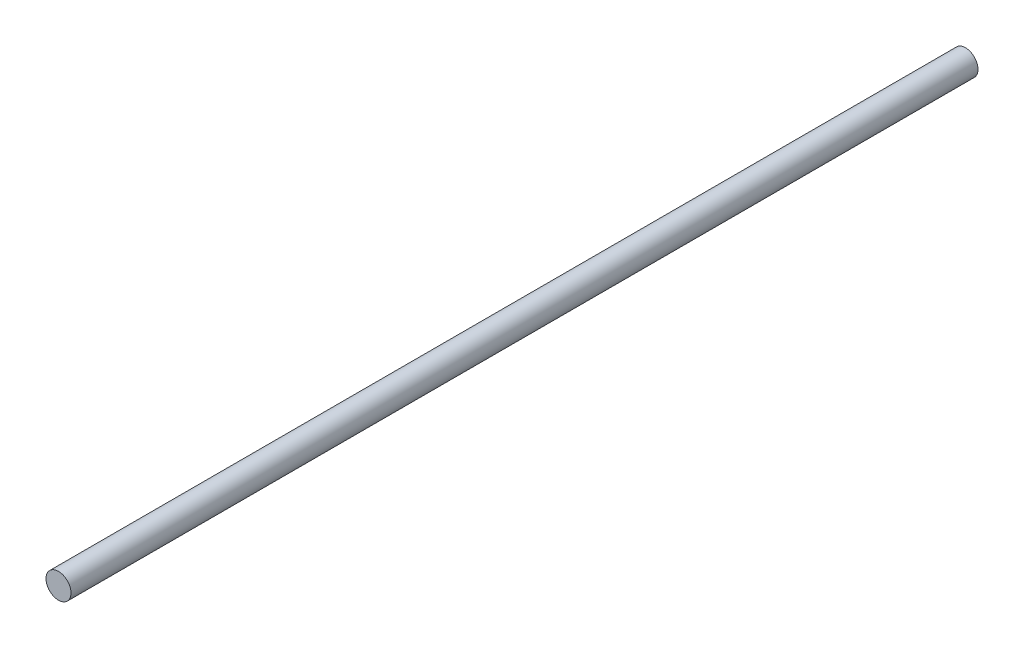
from build123d import *

# Parameters (mm, degrees)
SKETCH1_R           = 4
BOSS_EXTRUDE1_DEPTH = 290


with BuildPart() as part:
    # Sketch1 → Boss-Extrude1 (new body)
    with BuildSketch(Plane.XY):
        Circle(SKETCH1_R)
    extrude(amount=BOSS_EXTRUDE1_DEPTH)


solid = part.part
